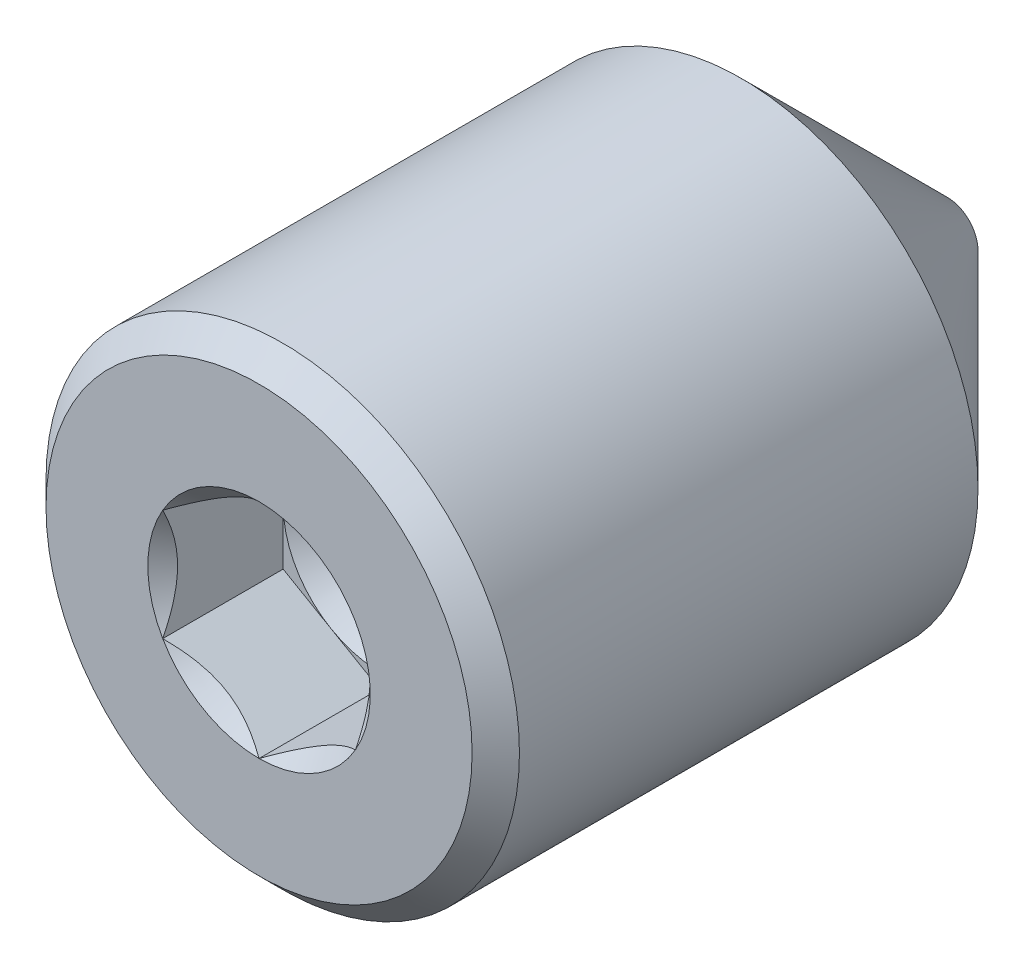
from build123d import *

# Parameters (mm, degrees)
CHAMFER1_SIZE      = 0.10922
CUT_EXTRUDE1_DEPTH = 0.555625


with BuildPart() as part:
    # Sketch2 → Revolve1 (revolve)
    with BuildSketch(Plane(origin=(0, 0, 0), x_dir=(0, 0, -1), z_dir=(1, 0, 0))):
        Polygon((-1.5875, 0), (1.5875, 0), (1.5875, 0.141986), (0.637286, 1.0922), (-1.5875, 1.0922), align=None)
    revolve(axis=Axis((0, 0, 1.5875), (0, 0, -1)))

    # Chamfer1
    chamfer1_edges = [part.edges().sort_by_distance(p)[0] for p in [
        (0, -1.0922, 1.5875),
    ]]
    chamfer(chamfer1_edges, length=CHAMFER1_SIZE)

    # Sketch3 → Cut-Extrude1 (cut)
    with BuildSketch(Plane.XY.offset(1.5875)):
        Polygon((0, -0.513264389), (0.4445, -0.256632195), (0.4445, 0.256632195), (0, 0.513264389), (-0.4445, 0.256632195), (-0.4445, -0.256632195), align=None)
    extrude(amount=-CUT_EXTRUDE1_DEPTH, mode=Mode.SUBTRACT)

    # Cut-Extrude2 cone 1 section (through the dimple's axis) → Cut-Extrude2 (revolve, cut)
    with BuildSketch(Plane(origin=(0, 0, 1.5875), x_dir=(0, -1, 0), z_dir=(1, 0, 0))):
        Polygon((0, 0), (0.513264389, 0), (0, 0.513264389), align=None)
    revolve(axis=Axis((0, 0, 1.5875), (0, 0, -1)), mode=Mode.SUBTRACT)

    # Cut-Extrude3 cone 1 section (through the dimple's axis) → Cut-Extrude3 (revolve, cut)
    with BuildSketch(Plane(origin=(0, 0, 1.031875), x_dir=(0, -1, 0), z_dir=(1, 0, 0))):
        Polygon((0, 0), (0.4445, 0), (0, 0.4445), align=None)
    revolve(axis=Axis((0, 0, 1.031875), (0, 0, -1)), mode=Mode.SUBTRACT)


solid = part.part
